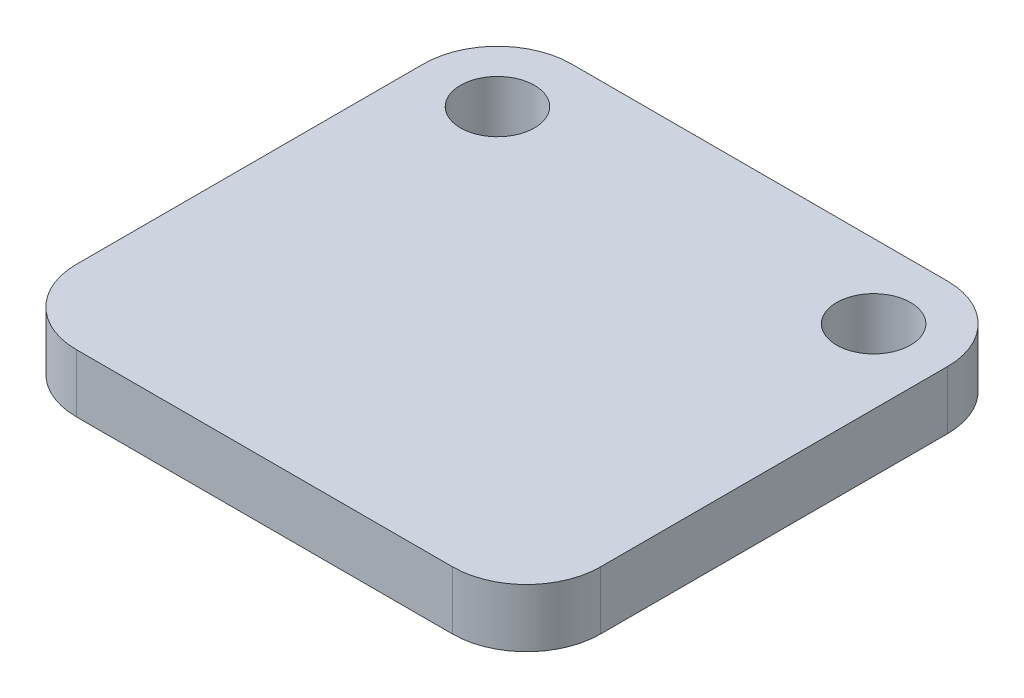
from build123d import *

# Parameters (mm, degrees)
SKETCH1_W           = 18
SKETCH1_H           = 17
BOSS_EXTRUDE1_DEPTH = 2
SKETCH2_R           = 1.27
CUT_EXTRUDE1_DEPTH  = 3
FILLET1_R           = 2.54


with BuildPart() as part:
    # Sketch1 → Boss-Extrude1 (new body)
    with BuildSketch(Plane(origin=(0, 0, 0), x_dir=(1, 0, 0), z_dir=(0, 1, 0))):
        with Locations((9, 8.5)):
            Rectangle(SKETCH1_W, SKETCH1_H)
    extrude(amount=BOSS_EXTRUDE1_DEPTH)

    # Sketch2 → Cut-Extrude1 (cut, through all)
    with BuildSketch(Plane(origin=(0, 2, 0), x_dir=(1, 0, 0), z_dir=(0, 1, 0))):
        with Locations((2.54, 14.46)):
            Circle(SKETCH2_R)
        with Locations((15.46, 14.46)):
            Circle(SKETCH2_R)
    extrude(amount=-CUT_EXTRUDE1_DEPTH, mode=Mode.SUBTRACT)

    # Fillet1
    fillet1_edges = [part.edges().sort_by_distance(p)[0] for p in [
        (0, 1, -17),
        (18, 1, -17),
        (18, 1, 0),
        (0, 1, 0),
    ]]
    fillet(fillet1_edges, radius=FILLET1_R)


solid = part.part
